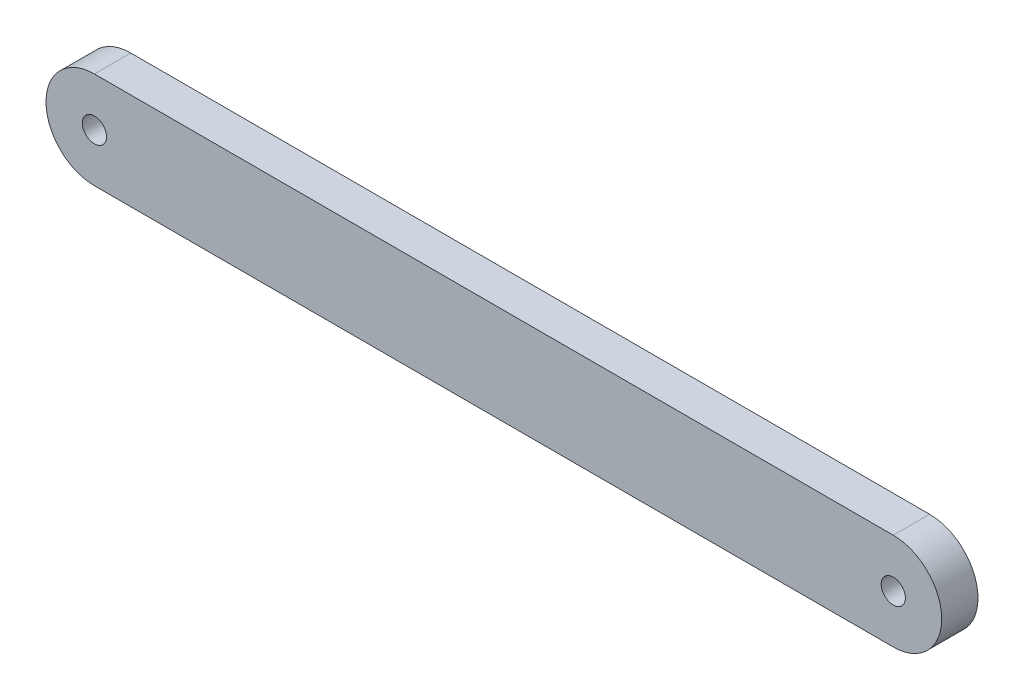
from build123d import *

# Parameters (mm, degrees)
ESQUISSE1_R        = 1
BOSS_EXTRU_1_DEPTH = 3


with BuildPart() as part:
    # Esquisse1 → Boss.-Extru.1 (new body)
    with BuildSketch(Plane.XY):
        with BuildLine():
            Line((70, 8), (4, 8))
            ThreePointArc((4, 8), (0, 4), (4, 0))
            Line((4, 0), (70, 0))
            ThreePointArc((70, 0), (74, 4), (70, 8))
        make_face()
        with Locations((4, 4)):
            Circle(ESQUISSE1_R, mode=Mode.SUBTRACT)
        with Locations((70, 4)):
            Circle(ESQUISSE1_R, mode=Mode.SUBTRACT)
    extrude(amount=BOSS_EXTRU_1_DEPTH)


solid = part.part
